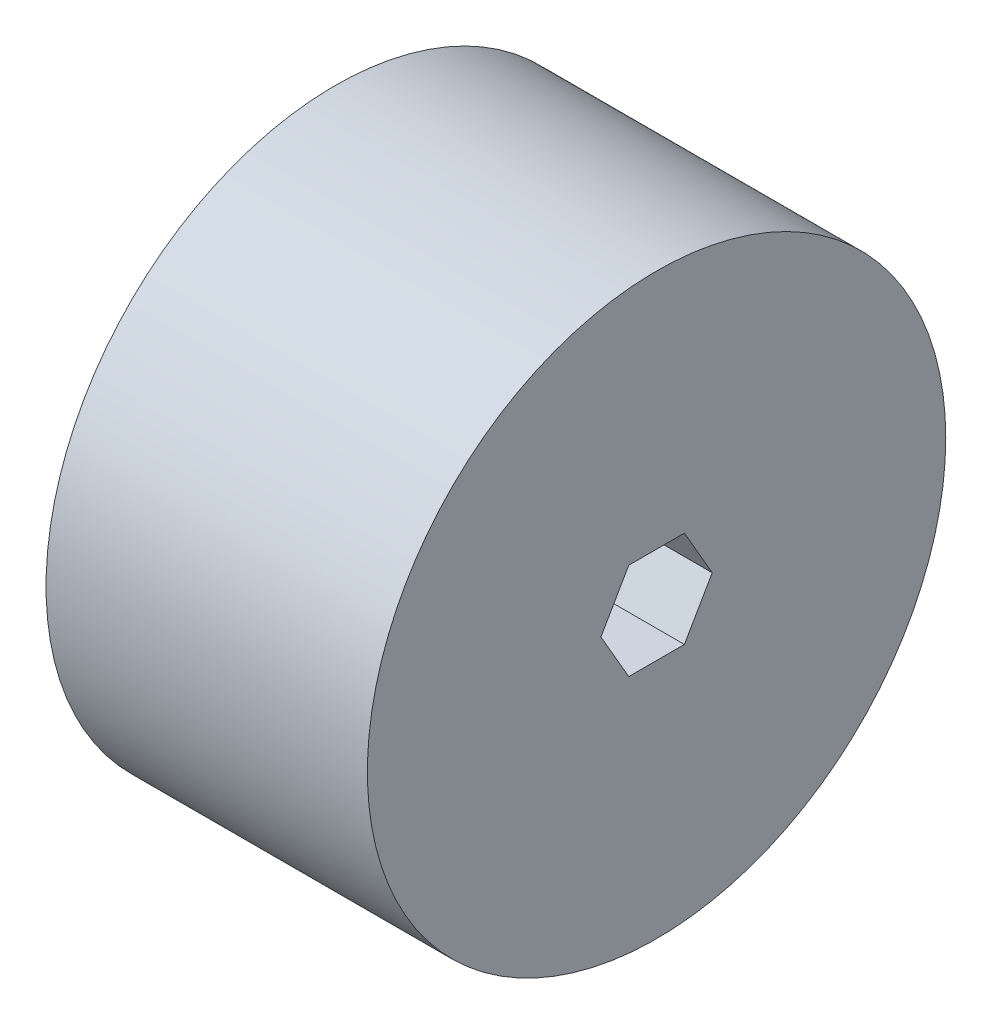
from build123d import *

# Parameters (mm, degrees)
SKETCH1_R           = 28.575
BOSS_EXTRUDE1_DEPTH = 31.75
CUT_EXTRUDE1_DEPTH  = 32.75


with BuildPart() as part:
    # Sketch1 → Boss-Extrude1 (new body)
    with BuildSketch(Plane(origin=(0, 0, 0), x_dir=(0, 0, -1), z_dir=(1, 0, 0))):
        Circle(SKETCH1_R)
    extrude(amount=BOSS_EXTRUDE1_DEPTH)

    # Sketch2 → Cut-Extrude1 (cut, through all)
    with BuildSketch(Plane(origin=(31.75, 0, 0), x_dir=(0, 0, -1), z_dir=(1, 0, 0))):
        Polygon((2.749630657, -4.7625), (5.499261314, 0), (2.749630657, 4.7625), (-2.749630657, 4.7625), (-5.499261314, 0), (-2.749630657, -4.7625), align=None)
    extrude(amount=-CUT_EXTRUDE1_DEPTH, mode=Mode.SUBTRACT)


solid = part.part
